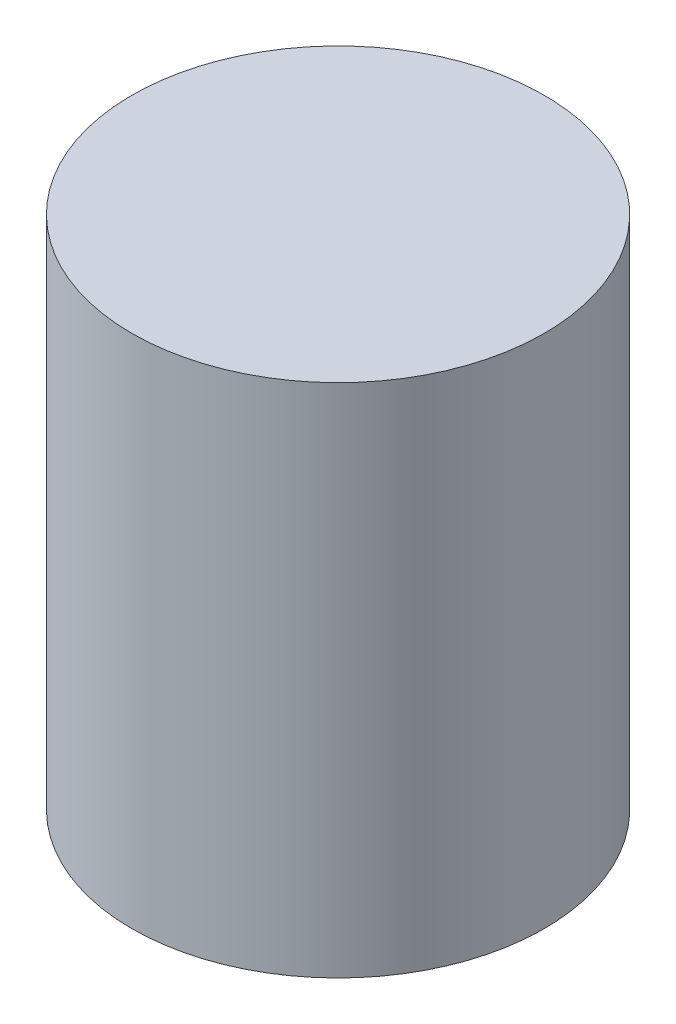
from build123d import *

# Parameters (mm, degrees)
SKETCH_1_R      = 20
EXTRUDE_1_DEPTH = 50


with BuildPart() as part:
    # 草图1 → 凸台-拉伸1 (new body)
    with BuildSketch(Plane(origin=(0, 0, 0), x_dir=(1, 0, 0), z_dir=(0, 1, 0))):
        Circle(SKETCH_1_R)
    extrude(amount=EXTRUDE_1_DEPTH)


solid = part.part
